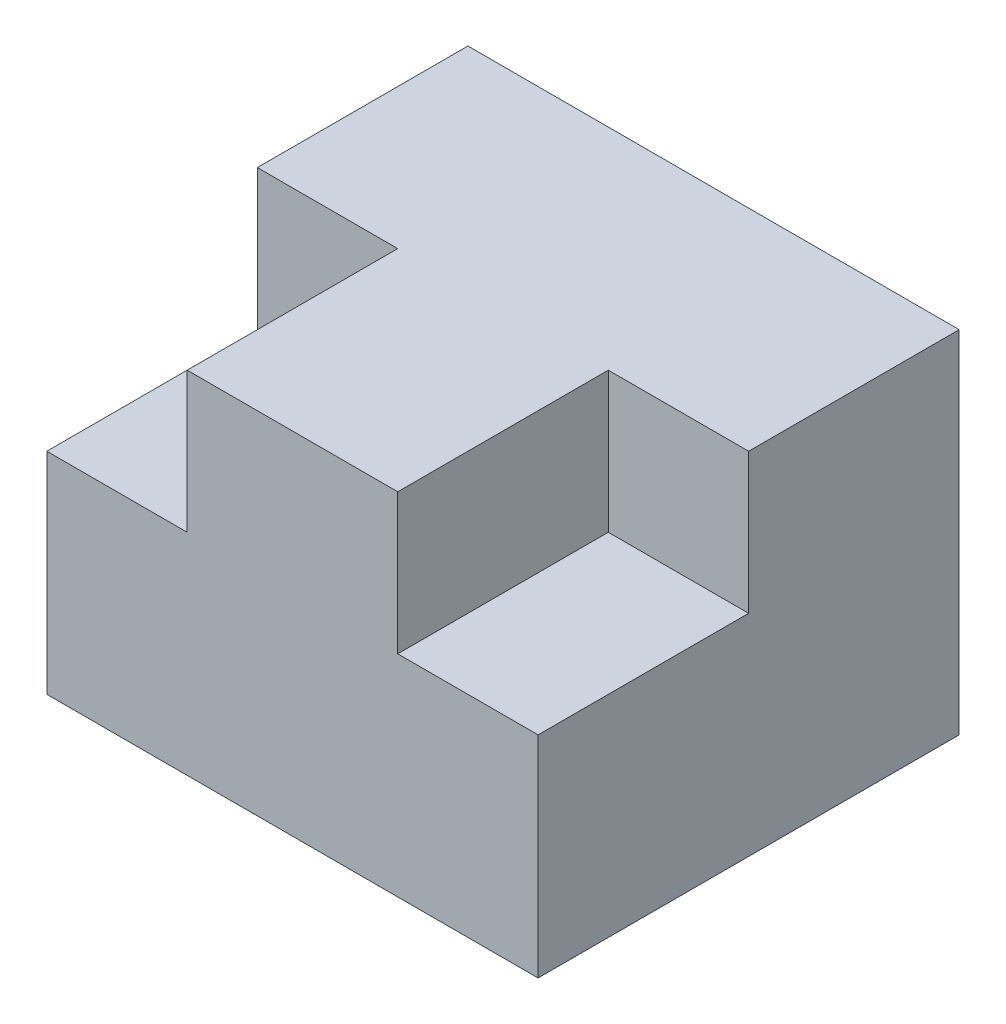
from build123d import *

# Parameters (mm, degrees)
SKETCH1_W           = 35
SKETCH1_H           = 25
BOSS_EXTRUDE1_DEPTH = 15
BOSS_EXTRUDE2_DEPTH = 15


with BuildPart() as part:
    # Sketch1 → Boss-Extrude1 (new body)
    with BuildSketch(Plane.XY):
        with Locations((-5.777889773, 0.039936102)):
            Rectangle(SKETCH1_W, SKETCH1_H)
    extrude(amount=-BOSS_EXTRUDE1_DEPTH)

    # Sketch2 → Boss-Extrude2 (add)
    with BuildSketch(Plane.XY):
        Polygon((-13.277889773, 12.539936102), (1.722110227, 12.539936102), (1.722110227, 2.539936102), (11.722110227, 2.539936102), (11.722110227, -12.460063898), (-23.277889773, -12.460063898), (-23.277889773, 2.539936102), (-13.277889773, 2.539936102), align=None)
    extrude(amount=BOSS_EXTRUDE2_DEPTH)


solid = part.part
